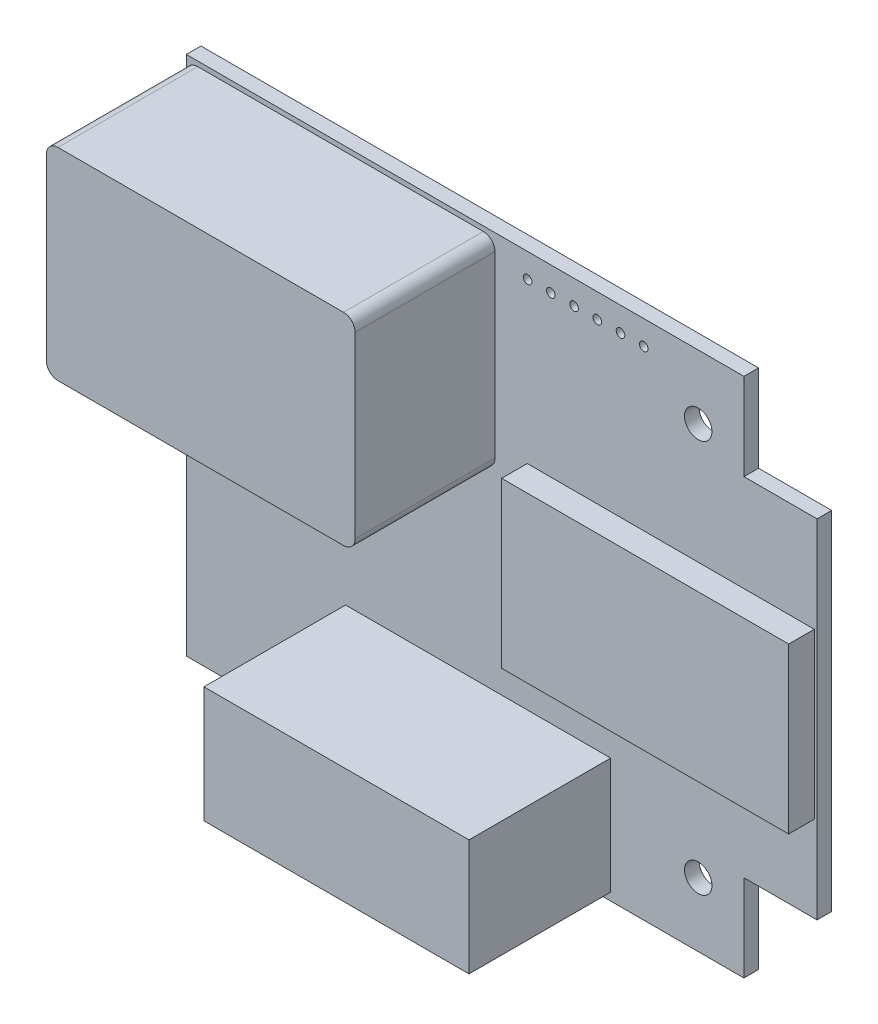
from build123d import *

# Parameters (mm, degrees)
SKETCH_20_R           = 1.5
BOSS_EXTRUDE1_DEPTH   = 1.6
SKETCH_17_R           = 0.4699
SKETCH_17_R_2         = 0.4875
CUT_EXTRUDE1_DEPTH    = 1.6
BOSS_EXTRUDE2_START   = -1.6
SKETCH_52_W           = 4.2
SKETCH_52_H           = 6.9
BOSS_EXTRUDE2_DEPTH   = 0.9
SKETCH_52_W_2         = 1.3208
SKETCH_52_H_2         = 3.3528
BOSS_EXTRUDE2_2_DEPTH = 0.9
BOSS_EXTRUDE2_3_DEPTH = 0.9
SKETCH_52_W_3         = 4
SKETCH_52_H_3         = 4
BOSS_EXTRUDE2_4_DEPTH = 0.9
SKETCH_52_W_4         = 3.2
SKETCH_52_H_4         = 1.3
BOSS_EXTRUDE2_5_DEPTH = 0.9
SKETCH_51_W           = 29
SKETCH_51_H           = 12.7
BOSS_EXTRUDE3_DEPTH   = 15.5
SKETCH_51_3_W         = 31.4
SKETCH_51_3_H         = 18
BOSS_EXTRUDE4_DEPTH   = 2.8
BOSS_EXTRUDE5_DEPTH   = 15.3


with BuildPart() as part:
    # Sketch 20 → Boss-Extrude1 (new body)
    with BuildSketch(Plane.XY):
        Polygon((0, 0), (61, 0), (61, 9.5), (69, 9.5), (69, 47.5), (61, 47.5), (61, 57), (0, 57), align=None)
        with Locations((56, 50)):
            Circle(SKETCH_20_R, mode=Mode.SUBTRACT)
        with Locations((56, 7)):
            Circle(SKETCH_20_R, mode=Mode.SUBTRACT)
        with Locations((13, 7)):
            Circle(SKETCH_20_R, mode=Mode.SUBTRACT)
    extrude(amount=-BOSS_EXTRUDE1_DEPTH)

    # Sketch 17 → Cut-Extrude1 (cut)
    with BuildSketch(Plane.XY):
        with Locations((50.038, 54.356)):
            Circle(SKETCH_17_R)
        with Locations((47.498, 54.356)):
            Circle(SKETCH_17_R)
        with Locations((44.958, 54.356)):
            Circle(SKETCH_17_R)
        with Locations((42.418, 54.356)):
            Circle(SKETCH_17_R)
        with Locations((39.878, 54.356)):
            Circle(SKETCH_17_R)
        with Locations((37.338, 54.356)):
            Circle(SKETCH_17_R)
        with Locations((23.772, 3.448)):
            Circle(SKETCH_17_R_2)
        with Locations((28.812, 3.448)):
            Circle(SKETCH_17_R_2)
        with Locations((18.732, 3.448)):
            Circle(SKETCH_17_R_2)
        with Locations((23.772, 10.948)):
            Circle(SKETCH_17_R_2)
        with Locations((28.812, 10.948)):
            Circle(SKETCH_17_R_2)
        with Locations((18.732, 10.948)):
            Circle(SKETCH_17_R_2)
        with Locations((44.072, 10.948)):
            Circle(SKETCH_17_R_2)
        with Locations((44.072, 3.448)):
            Circle(SKETCH_17_R_2)
        with Locations((44.072, 7.258)):
            Circle(SKETCH_17_R_2)
    extrude(amount=-CUT_EXTRUDE1_DEPTH, mode=Mode.SUBTRACT)

    # Sketch 51_3 → Boss-Extrude4 (add)
    with BuildSketch(Plane.XY):
        with Locations((52.994, 27.89)):
            Rectangle(SKETCH_51_3_W, SKETCH_51_3_H)
    extrude(amount=BOSS_EXTRUDE4_DEPTH)


with BuildPart() as body_2:
    # Sketch 52 → Boss-Extrude2 (new body)
    with BuildSketch(Plane.XY.offset(BOSS_EXTRUDE2_START)):
        with Locations((33.69, 48.646)):
            Rectangle(SKETCH_52_W, SKETCH_52_H)
    extrude(amount=-BOSS_EXTRUDE2_DEPTH)


with BuildPart() as body_3:
    # Sketch 52 → Boss-Extrude2 2 (new body)
    with BuildSketch(Plane.XY.offset(BOSS_EXTRUDE2_START)):
        with Locations((46.482, 9.652)):
            Rectangle(SKETCH_52_W_2, SKETCH_52_H_2)
    extrude(amount=-BOSS_EXTRUDE2_2_DEPTH)


with BuildPart() as body_4:
    # Sketch 52 → Boss-Extrude2 3 (new body)
    with BuildSketch(Plane.XY.offset(BOSS_EXTRUDE2_START)):
        with Locations((46.482, 4.826)):
            Rectangle(SKETCH_52_W_2, SKETCH_52_H_2)
    extrude(amount=-BOSS_EXTRUDE2_3_DEPTH)


with BuildPart() as body_5:
    # Sketch 52 → Boss-Extrude2 4 (new body)
    with BuildSketch(Plane.XY.offset(BOSS_EXTRUDE2_START)):
        with Locations((34.242, 26.046)):
            Rectangle(SKETCH_52_W_3, SKETCH_52_H_3)
    extrude(amount=-BOSS_EXTRUDE2_4_DEPTH)


with BuildPart() as body_6:
    # Sketch 52 → Boss-Extrude2 5 (new body)
    with BuildSketch(Plane.XY.offset(BOSS_EXTRUDE2_START)):
        with Locations((34.748, 20.356)):
            Rectangle(SKETCH_52_W_4, SKETCH_52_H_4)
    extrude(amount=-BOSS_EXTRUDE2_5_DEPTH)


with BuildPart() as body_7:
    # Sketch 51 → Boss-Extrude3 (new body)
    with BuildSketch(Plane.XY):
        with Locations((31.922, 7.198)):
            Rectangle(SKETCH_51_W, SKETCH_51_H)
    extrude(amount=BOSS_EXTRUDE3_DEPTH)


with BuildPart() as body_8:
    # Sketch 21 → Boss-Extrude5 (new body)
    with BuildSketch(Plane.XY):
        with BuildLine():
            Line((1.252, 56.47), (32.494, 56.47))
            ThreePointArc((32.494, 56.47), (33.392017, 56.098017), (33.764, 55.2))
            Line((33.764, 55.2), (33.764, 35.642))
            ThreePointArc((33.764, 35.642), (33.392017, 34.743983), (32.494, 34.372))
            Line((32.494, 34.372), (1.252, 34.372))
            ThreePointArc((1.252, 34.372), (0.353983, 34.743983), (-0.018, 35.642))
            Line((-0.018, 35.642), (-0.018, 55.2))
            ThreePointArc((-0.018, 55.2), (0.353983, 56.098017), (1.252, 56.47))
        make_face()
    extrude(amount=BOSS_EXTRUDE5_DEPTH)


solid = Compound([part.part, body_2.part, body_3.part, body_4.part, body_5.part, body_6.part, body_7.part, body_8.part])
